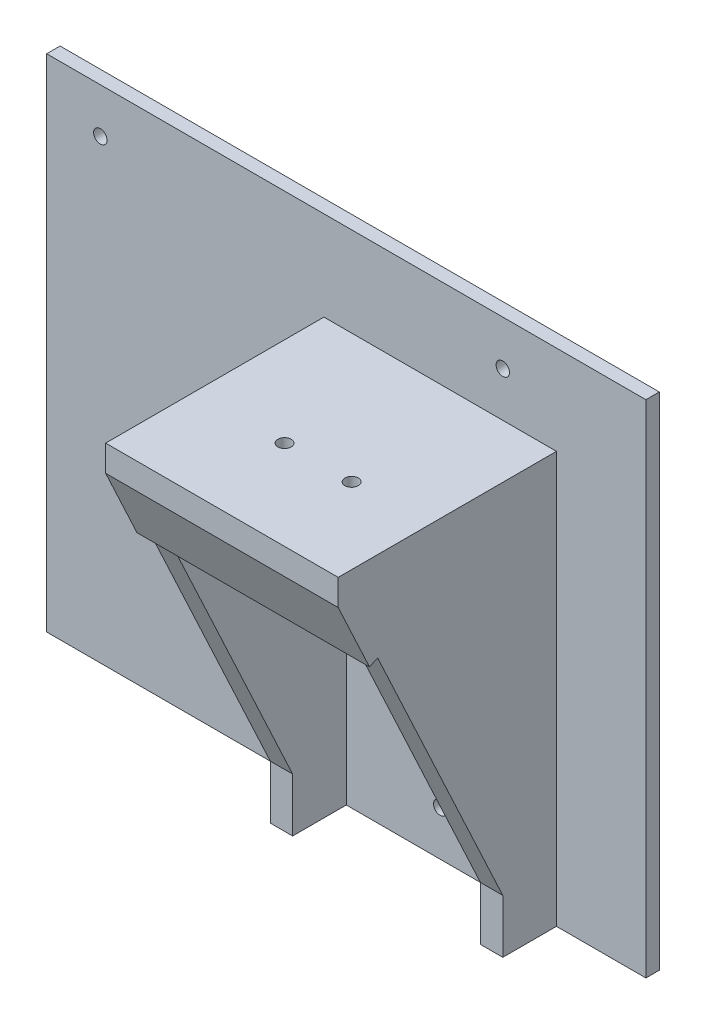
from build123d import *

# Parameters (mm, degrees)
SKETCH1_W           = 72
SKETCH1_H           = 92
BOSS_EXTRUDE1_DEPTH = 3
SKETCH2_W           = 5
SKETCH2_H           = 92
BOSS_EXTRUDE2_DEPTH = 47
BOSS_EXTRUDE3_REACH = 52
SKETCH3_W           = 52
SKETCH3_H           = 20
CUT_EXTRUDE3_REACH  = 54
SKETCH8_W           = 52
SKETCH8_H           = 16.552945357
BOSS_EXTRUDE5_DEPTH = 2
SKETCH9_W           = 52
SKETCH9_H           = 5
SKETCH9_H_2         = 0.845770931
BOSS_EXTRUDE6_DEPTH = 1.812366
SKETCH10_W          = 42
SKETCH10_H          = 40
CUT_EXTRUDE4_DEPTH  = 17
CUT_EXTRUDE5_REACH  = 94
SKETCH12_R          = 1.5
SKETCH13_W          = 72
SKETCH13_H          = 3
BOSS_EXTRUDE7_DEPTH = 20
SKETCH15_W          = 3
SKETCH15_H          = 112
BOSS_EXTRUDE8_DEPTH = 20
SKETCH16_W          = 3
SKETCH16_H          = 112
BOSS_EXTRUDE9_DEPTH = 42
CUT_EXTRUDE9_REACH  = 5
SKETCH14_R          = 1.5


with BuildPart() as part:
    # Sketch1 → Boss-Extrude1 (new body)
    with BuildSketch(Plane.XY):
        Rectangle(SKETCH1_W, SKETCH1_H)
    extrude(amount=BOSS_EXTRUDE1_DEPTH)

    # Sketch2 → Boss-Extrude2 (add)
    with BuildSketch(Plane.XY.offset(3)):
        with Locations((33.5, 0)):
            Rectangle(SKETCH2_W, SKETCH2_H)
        with Locations((-13.5, 0)):
            Rectangle(SKETCH2_W, SKETCH2_H)
    extrude(amount=BOSS_EXTRUDE2_DEPTH)

    # Sketch3 → Boss-Extrude3 (add, up to next)
    with BuildSketch(Plane.XY.offset(50), mode=Mode.PRIVATE) as boss_extrude3_sk1:
        with Locations((10, 36)):
            Rectangle(SKETCH3_W, SKETCH3_H)
    boss_extrude3_tool1 = extrude(boss_extrude3_sk1.sketch, amount=-BOSS_EXTRUDE3_REACH, mode=Mode.PRIVATE) - part.part
    add(boss_extrude3_tool1.solids().sort_by_distance((10, 36, 50))[0])

    # Sketch7 → Cut-Extrude3 (cut, up to next)
    with BuildSketch(Plane.ZY.offset(16), mode=Mode.PRIVATE) as cut_extrude3_sk1:
        Polygon((50, 41), (15, -34), (15, -46), (50, -46), align=None)
    cut_extrude3_tool1 = extrude(cut_extrude3_sk1.sketch, amount=-CUT_EXTRUDE3_REACH, mode=Mode.PRIVATE) & part.part
    add(cut_extrude3_tool1.solids().sort_by_distance((-16, -16.515152, 36.919192))[0], mode=Mode.SUBTRACT)

    # Sketch8 → Boss-Extrude5 (add)
    with BuildSketch(Plane(origin=(0, -11.828467153, 25.346715328), x_dir=(1, 0, 0), z_dir=(0, -0.422885465, 0.90618314))):
        with Locations((10, 50.021309328)):
            Rectangle(SKETCH8_W, SKETCH8_H)
    extrude(amount=BOSS_EXTRUDE5_DEPTH)

    # Sketch9 → Boss-Extrude6 (add)
    with BuildSketch(Plane.XY.offset(50)):
        with Locations((10, 43.5)):
            Rectangle(SKETCH9_W, SKETCH9_H)
        with Locations((10, 40.577114534)):
            Rectangle(SKETCH9_W, SKETCH9_H_2)
    extrude(amount=BOSS_EXTRUDE6_DEPTH)

    # Sketch10 → Cut-Extrude4 (cut)
    with BuildSketch(Plane.XZ.offset(-26)):
        with Locations((10, 23)):
            Rectangle(SKETCH10_W, SKETCH10_H)
    extrude(amount=-CUT_EXTRUDE4_DEPTH, mode=Mode.SUBTRACT)

    # Sketch12 → Cut-Extrude5 (cut, up to next)
    with BuildSketch(Plane(origin=(0, 46, 0), x_dir=(1, 0, 0), z_dir=(0, 1, 0)), mode=Mode.PRIVATE) as cut_extrude5_sk1:
        with Locations((4, -31.81236628)):
            Circle(SKETCH12_R)
    cut_extrude5_tool1 = extrude(cut_extrude5_sk1.sketch, amount=-CUT_EXTRUDE5_REACH, mode=Mode.PRIVATE) & part.part
    add(cut_extrude5_tool1.solids().sort_by_distance((4, 46, 31.812366))[0], mode=Mode.SUBTRACT)
    # Sketch12 → Cut-Extrude5 (cut, up to next)
    with BuildSketch(Plane(origin=(0, 46, 0), x_dir=(1, 0, 0), z_dir=(0, 1, 0)), mode=Mode.PRIVATE) as cut_extrude5_sk2:
        with Locations((19, -31.81236628)):
            Circle(SKETCH12_R)
    cut_extrude5_tool2 = extrude(cut_extrude5_sk2.sketch, amount=-CUT_EXTRUDE5_REACH, mode=Mode.PRIVATE) & part.part
    add(cut_extrude5_tool2.solids().sort_by_distance((19, 46, 31.812366))[0], mode=Mode.SUBTRACT)

    # Sketch13 → Boss-Extrude7 (add)
    with BuildSketch(Plane(origin=(0, 46, 0), x_dir=(1, 0, 0), z_dir=(0, 1, 0))):
        with Locations((0, -1.5)):
            Rectangle(SKETCH13_W, SKETCH13_H)
    extrude(amount=BOSS_EXTRUDE7_DEPTH)

    # Sketch15 → Boss-Extrude8 (add)
    with BuildSketch(Plane(origin=(36, 0, 0), x_dir=(0, 0, -1), z_dir=(1, 0, 0))):
        with Locations((-1.5, 10)):
            Rectangle(SKETCH15_W, SKETCH15_H)
    extrude(amount=BOSS_EXTRUDE8_DEPTH)

    # Sketch16 → Boss-Extrude9 (add)
    with BuildSketch(Plane.ZY.offset(36)):
        with Locations((1.5, 10)):
            Rectangle(SKETCH16_W, SKETCH16_H)
    extrude(amount=BOSS_EXTRUDE9_DEPTH)

    # Sketch14 → Cut-Extrude9 (cut, up to next)
    with BuildSketch(Plane.XY.offset(3), mode=Mode.PRIVATE) as cut_extrude9_sk1:
        with Locations((24, 56)):
            Circle(SKETCH14_R)
    cut_extrude9_tool1 = extrude(cut_extrude9_sk1.sketch, amount=-CUT_EXTRUDE9_REACH, mode=Mode.PRIVATE) & part.part
    add(cut_extrude9_tool1.solids().sort_by_distance((24, 56, 3))[0], mode=Mode.SUBTRACT)
    # Sketch14 → Cut-Extrude9 (cut, up to next)
    with BuildSketch(Plane.XY.offset(3), mode=Mode.PRIVATE) as cut_extrude9_sk2:
        with Locations((10, -36)):
            Circle(SKETCH14_R)
    cut_extrude9_tool2 = extrude(cut_extrude9_sk2.sketch, amount=-CUT_EXTRUDE9_REACH, mode=Mode.PRIVATE) & part.part
    add(cut_extrude9_tool2.solids().sort_by_distance((10, -36, 3))[0], mode=Mode.SUBTRACT)
    # Sketch14 → Cut-Extrude9 (cut, up to next)
    with BuildSketch(Plane.XY.offset(3), mode=Mode.PRIVATE) as cut_extrude9_sk3:
        with Locations((-66, 56)):
            Circle(SKETCH14_R)
    cut_extrude9_tool3 = extrude(cut_extrude9_sk3.sketch, amount=-CUT_EXTRUDE9_REACH, mode=Mode.PRIVATE) & part.part
    add(cut_extrude9_tool3.solids().sort_by_distance((-66, 56, 3))[0], mode=Mode.SUBTRACT)


solid = part.part
